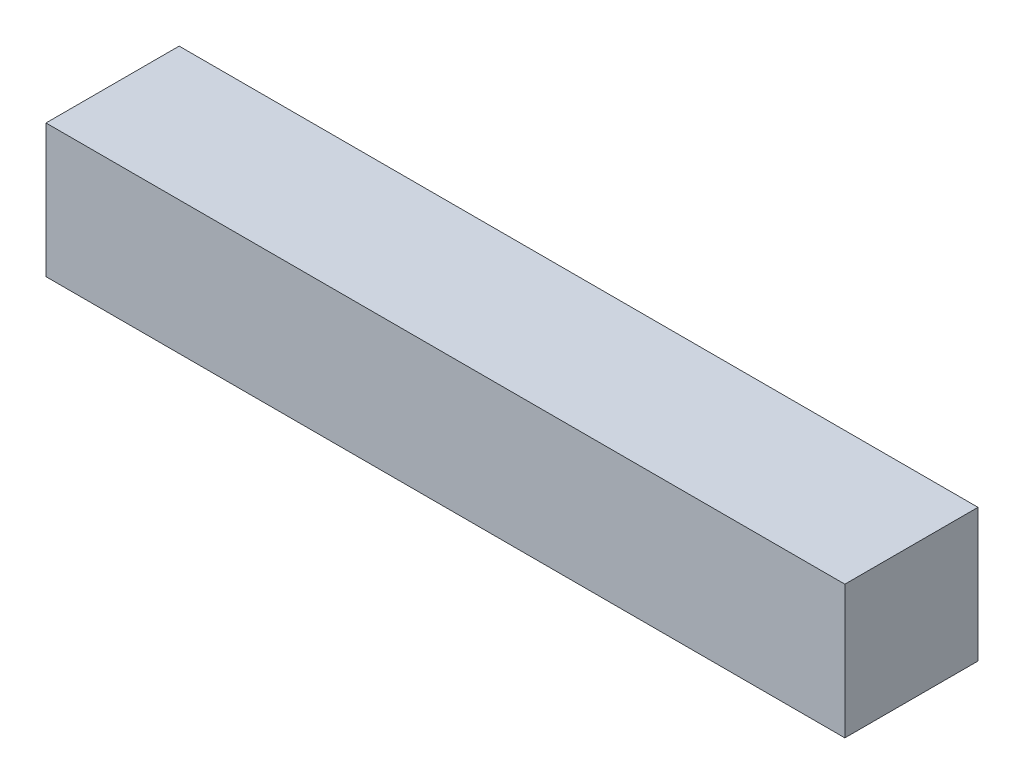
from build123d import *

# Parameters (mm, degrees)
SKETCH1_W           = 25.4
SKETCH1_H           = 25.4
BOSS_EXTRUDE1_DEPTH = 152.4


with BuildPart() as part:
    # Sketch1 → Boss-Extrude1 (new body)
    with BuildSketch(Plane(origin=(0, 0, 0), x_dir=(0, 0, -1), z_dir=(1, 0, 0))):
        with Locations((12.7, 12.7)):
            Rectangle(SKETCH1_W, SKETCH1_H)
    extrude(amount=BOSS_EXTRUDE1_DEPTH)


solid = part.part
